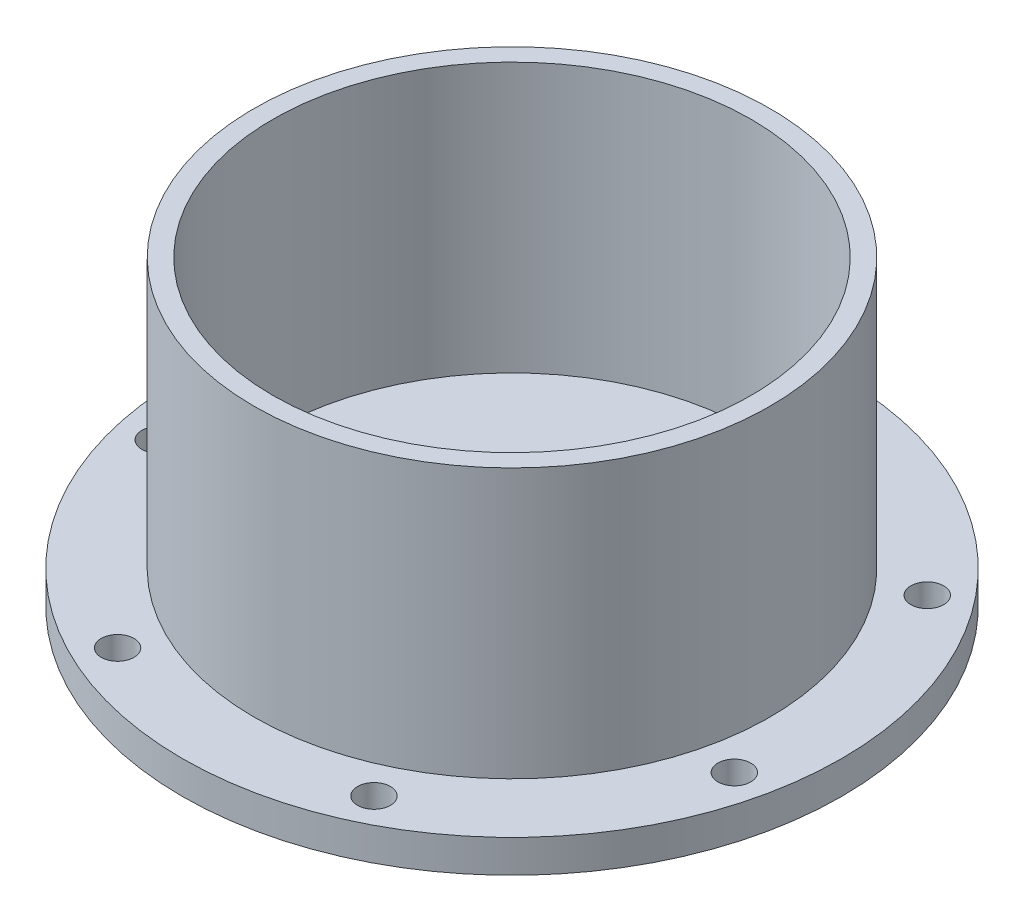
from build123d import *

# Parameters (mm, degrees)
SKETCH2_R           = 35.15
SKETCH2_R_2         = 1.75
BOSS_EXTRUDE1_DEPTH = 3.5
SKETCH3_R           = 27.5
SKETCH3_R_2         = 25.5
BOSS_EXTRUDE2_DEPTH = 28.7


with BuildPart() as part:
    # Sketch2 → Boss-Extrude1 (new body)
    with BuildSketch(Plane(origin=(0, 0, 0), x_dir=(1, 0, 0), z_dir=(0, 1, 0))):
        Circle(SKETCH2_R)
        with Locations((0, 31.5)):
            Circle(SKETCH2_R_2, mode=Mode.SUBTRACT)
        with Locations((24.627691698, 19.639928759)):
            Circle(SKETCH2_R_2, mode=Mode.SUBTRACT)
        with Locations((30.710229234, -7.00940942)):
            Circle(SKETCH2_R_2, mode=Mode.SUBTRACT)
        with Locations((13.667337782, -28.380519339)):
            Circle(SKETCH2_R_2, mode=Mode.SUBTRACT)
        with Locations((-13.667337782, -28.380519339)):
            Circle(SKETCH2_R_2, mode=Mode.SUBTRACT)
        with Locations((-30.710229234, -7.00940942)):
            Circle(SKETCH2_R_2, mode=Mode.SUBTRACT)
        with Locations((-24.627691698, 19.639928759)):
            Circle(SKETCH2_R_2, mode=Mode.SUBTRACT)
    extrude(amount=BOSS_EXTRUDE1_DEPTH)

    # Sketch3 → Boss-Extrude2 (add)
    with BuildSketch(Plane(origin=(0, 3.5, 0), x_dir=(1, 0, 0), z_dir=(0, 1, 0))):
        Circle(SKETCH3_R)
        Circle(SKETCH3_R_2, mode=Mode.SUBTRACT)
    extrude(amount=BOSS_EXTRUDE2_DEPTH)


solid = part.part
